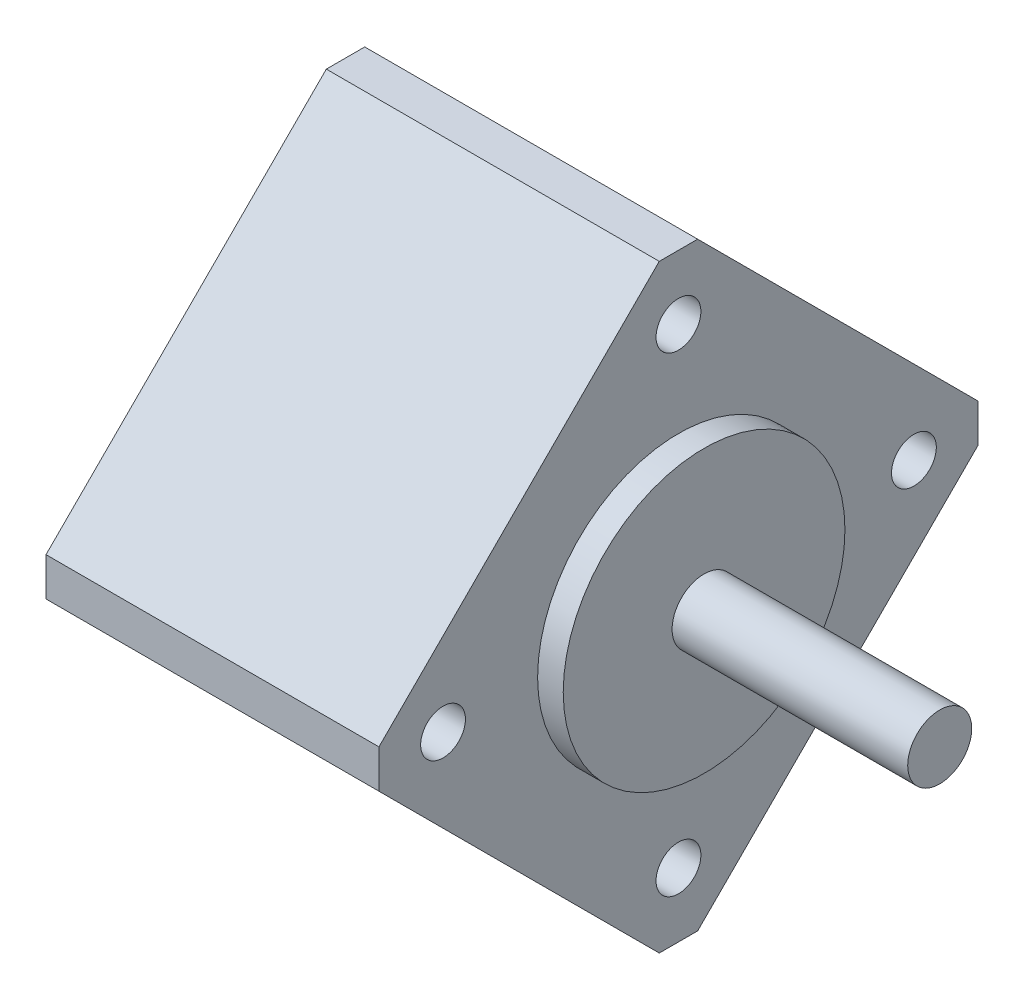
from build123d import *

# Parameters (mm, degrees)
SKETCH2_W           = 18.40000003
SKETCH2_H           = 2.499999953
SKETCH2_W_2         = 2.000000064
SKETCH2_H_2         = 10.999999971
SKETCH3_R           = 1.75
BOSS_EXTRUDE1_DEPTH = 26


with BuildPart() as part:
    # Sketch2 → Revolve1 (revolve)
    with BuildSketch(Plane.XY):
        with Locations((9.200000015, 1.249999977)):
            Rectangle(SKETCH2_W, SKETCH2_H)
        with Locations((-1.000000032, 5.499999986)):
            Rectangle(SKETCH2_W_2, SKETCH2_H_2)
    revolve(axis=Axis((0, 0, 0), (1, 0, 0)))

    # Sketch3 → Boss-Extrude1 (add)
    with BuildSketch(Plane.ZY.offset(2.000000064)):
        Polygon((0, 23.390158698), (1.5, 23.390158698), (23.390158698, 1.5), (23.390158698, 0), (23.390158698, -1.5), (1.5, -23.390158698), (0, -23.390158698), (-1.5, -23.390158698), (-23.390158698, -1.5), (-23.390158698, 0), (-23.390158698, 1.5), (-1.5, 23.390158698), align=None)
        with Locations((0, 18.384776311)):
            Circle(SKETCH3_R, mode=Mode.SUBTRACT)
        with Locations((18.384776311, 0)):
            Circle(SKETCH3_R, mode=Mode.SUBTRACT)
        with Locations((0, -18.384776311)):
            Circle(SKETCH3_R, mode=Mode.SUBTRACT)
        with Locations((-18.384776311, 0)):
            Circle(SKETCH3_R, mode=Mode.SUBTRACT)
    extrude(amount=BOSS_EXTRUDE1_DEPTH)


solid = part.part
